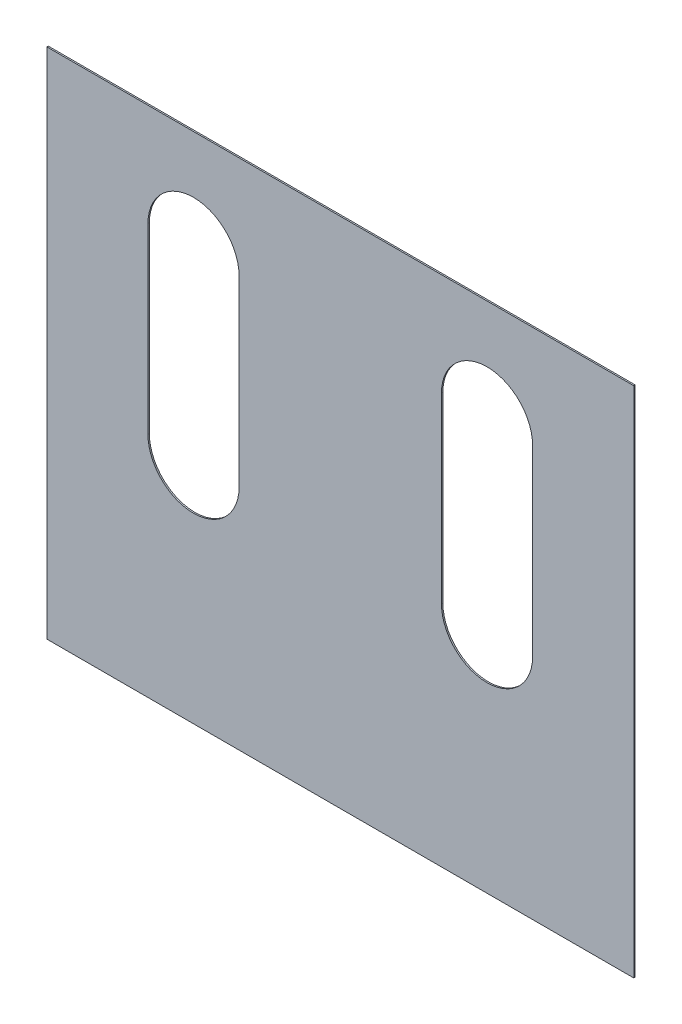
from build123d import *

# Parameters (mm, degrees)
SKETCH1_W           = 2616.2
SKETCH1_H           = 2286
BOSS_EXTRUDE1_DEPTH = 6.35


with BuildPart() as part:
    # Sketch1 → Boss-Extrude1 (new body)
    with BuildSketch(Plane.XY):
        Rectangle(SKETCH1_W, SKETCH1_H)
        with BuildLine():
            Line((-450.85, 685.8), (-450.85, -127))
            ThreePointArc((-450.85, -127), (-654.05, -330.2), (-857.25, -127))
            Line((-857.25, -127), (-857.25, 685.8))
            ThreePointArc((-857.25, 685.8), (-654.05, 889), (-450.85, 685.8))
        make_face(mode=Mode.SUBTRACT)
        with BuildLine():
            Line((857.25, 685.8), (857.25, -127))
            ThreePointArc((857.25, -127), (654.05, -330.2), (450.85, -127))
            Line((450.85, -127), (450.85, 685.8))
            ThreePointArc((450.85, 685.8), (654.05, 889), (857.25, 685.8))
        make_face(mode=Mode.SUBTRACT)
    extrude(amount=BOSS_EXTRUDE1_DEPTH)


solid = part.part
